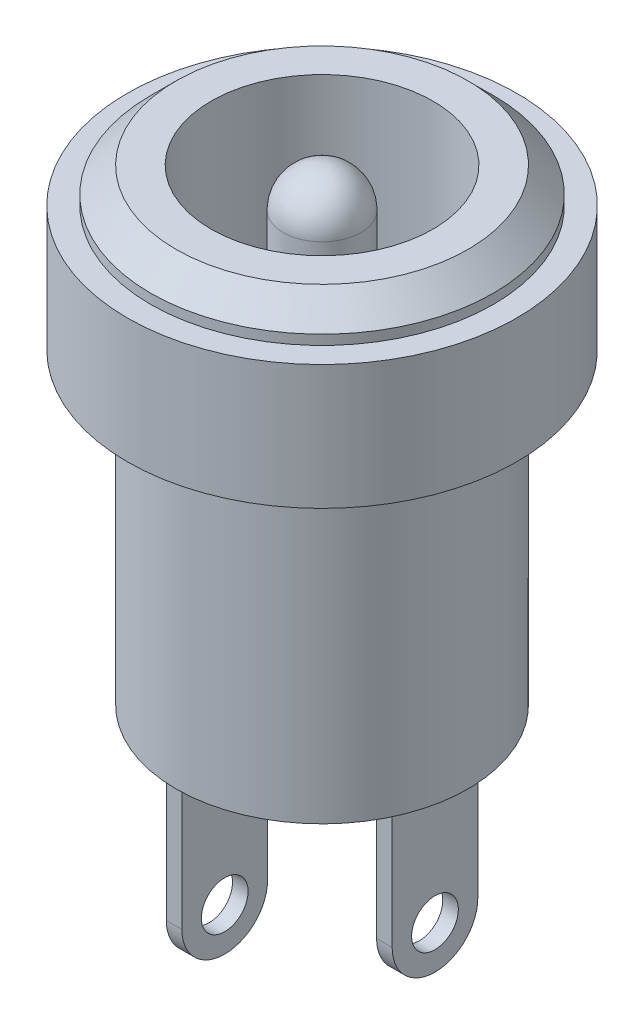
from build123d import *

# Parameters (mm, degrees)
ESQUISSE2_R             = 2.85
ESQUISSE2_R_2           = 1
ENL_V_MAT_EXTRU_1_DEPTH = 10
CONG_1_R                = 1
ESQUISSE3_W             = 0.4
ESQUISSE3_H             = 2.2
BOSS_EXTRU_1_DEPTH      = 6.8
ENL_V_MAT_EXTRU_2_REACH = 9.9
ESQUISSE4_R             = 0.6
ENL_V_MAT_EXTRU_3_REACH = 9.9
ESQUISSE6_R             = 0.6


with BuildPart() as part:
    # Esquisse1 → Révolution1 (revolve)
    with BuildSketch(Plane.XY):
        Polygon((0, -6), (-3.75, -6), (-3.75, 1.9), (-5, 1.9), (-5, 5.1), (-4.4, 5.1), (-4.4, 5.35), (-3.75, 6), (0, 6), align=None)
    revolve(axis=Axis((0, 6, 0), (0, -1, 0)))

    # Esquisse2 → Enlèv. mat.-Extru.1 (cut)
    with BuildSketch(Plane(origin=(0, 6, 0), x_dir=(1, 0, 0), z_dir=(0, 1, 0))):
        Circle(ESQUISSE2_R)
        Circle(ESQUISSE2_R_2, mode=Mode.SUBTRACT)
    extrude(amount=-ENL_V_MAT_EXTRU_1_DEPTH, mode=Mode.SUBTRACT)

    # Congé1
    cong_1_edges = [part.edges().sort_by_distance(p)[0] for p in [
        (-1, 6, 0),
    ]]
    fillet(cong_1_edges, radius=CONG_1_R)

    # Esquisse3 → Boss.-Extru.1 (add)
    with BuildSketch(Plane.XZ.offset(6)):
        with Locations((-2.7, 0)):
            Rectangle(ESQUISSE3_W, ESQUISSE3_H)
        with Locations((2.7, 0)):
            Rectangle(ESQUISSE3_W, ESQUISSE3_H)
    extrude(amount=BOSS_EXTRU_1_DEPTH)

    # Esquisse4 → Enlèv. mat.-Extru.2 (cut, up to next)
    with BuildSketch(Plane(origin=(2.9, 0, 0), x_dir=(0, 0, -1), z_dir=(1, 0, 0)), mode=Mode.PRIVATE) as enl_v_mat_extru_2_sk1:
        with BuildLine():
            ThreePointArc((1.1, -9.4), (0, -10.5), (-1.1, -9.4))
            Line((-1.1, -9.4), (-1.1, -12.8))
            Line((-1.1, -12.8), (1.1, -12.8))
            Line((1.1, -12.8), (1.1, -9.4))
        make_face()
    enl_v_mat_extru_2_tool1 = extrude(enl_v_mat_extru_2_sk1.sketch, amount=-ENL_V_MAT_EXTRU_2_REACH, mode=Mode.PRIVATE) & part.part
    add(enl_v_mat_extru_2_tool1.solids().sort_by_distance((2.9, -11.520085, 0))[0], mode=Mode.SUBTRACT)
    # Esquisse4 → Enlèv. mat.-Extru.2 (cut, up to next)
    with BuildSketch(Plane(origin=(2.9, 0, 0), x_dir=(0, 0, -1), z_dir=(1, 0, 0)), mode=Mode.PRIVATE) as enl_v_mat_extru_2_sk2:
        with Locations((0, -9.4)):
            Circle(ESQUISSE4_R)
    enl_v_mat_extru_2_tool2 = extrude(enl_v_mat_extru_2_sk2.sketch, amount=-ENL_V_MAT_EXTRU_2_REACH, mode=Mode.PRIVATE) & part.part
    add(enl_v_mat_extru_2_tool2.solids().sort_by_distance((2.9, -9.4, 0))[0], mode=Mode.SUBTRACT)

    # Esquisse6 → Enlèv. mat.-Extru.3 (cut, up to next)
    with BuildSketch(Plane.ZY.offset(2.9), mode=Mode.PRIVATE) as enl_v_mat_extru_3_sk1:
        with BuildLine():
            ThreePointArc((0, -12.8), (-0.777817459, -12.477817459), (-1.1, -11.7))
            Line((-1.1, -11.7), (-1.1, -12.8))
            Line((-1.1, -12.8), (0, -12.8))
        make_face()
    enl_v_mat_extru_3_tool1 = extrude(enl_v_mat_extru_3_sk1.sketch, amount=-ENL_V_MAT_EXTRU_3_REACH, mode=Mode.PRIVATE) & part.part
    add(enl_v_mat_extru_3_tool1.solids().sort_by_distance((-2.9, -12.554295, -0.854295))[0], mode=Mode.SUBTRACT)
    # Esquisse6 → Enlèv. mat.-Extru.3 (cut, up to next)
    with BuildSketch(Plane.ZY.offset(2.9), mode=Mode.PRIVATE) as enl_v_mat_extru_3_sk2:
        with BuildLine():
            ThreePointArc((1.1, -11.7), (0.777817459, -12.477817459), (0, -12.8))
            Line((0, -12.8), (1.1, -12.8))
            Line((1.1, -12.8), (1.1, -11.7))
        make_face()
    enl_v_mat_extru_3_tool2 = extrude(enl_v_mat_extru_3_sk2.sketch, amount=-ENL_V_MAT_EXTRU_3_REACH, mode=Mode.PRIVATE) & part.part
    add(enl_v_mat_extru_3_tool2.solids().sort_by_distance((-2.9, -12.554295, 0.854295))[0], mode=Mode.SUBTRACT)
    # Esquisse6 → Enlèv. mat.-Extru.3 (cut, up to next)
    with BuildSketch(Plane.ZY.offset(2.9), mode=Mode.PRIVATE) as enl_v_mat_extru_3_sk3:
        with Locations((0, -11.7)):
            Circle(ESQUISSE6_R)
    enl_v_mat_extru_3_tool3 = extrude(enl_v_mat_extru_3_sk3.sketch, amount=-ENL_V_MAT_EXTRU_3_REACH, mode=Mode.PRIVATE) & part.part
    add(enl_v_mat_extru_3_tool3.solids().sort_by_distance((-2.9, -11.7, 0))[0], mode=Mode.SUBTRACT)


solid = part.part
